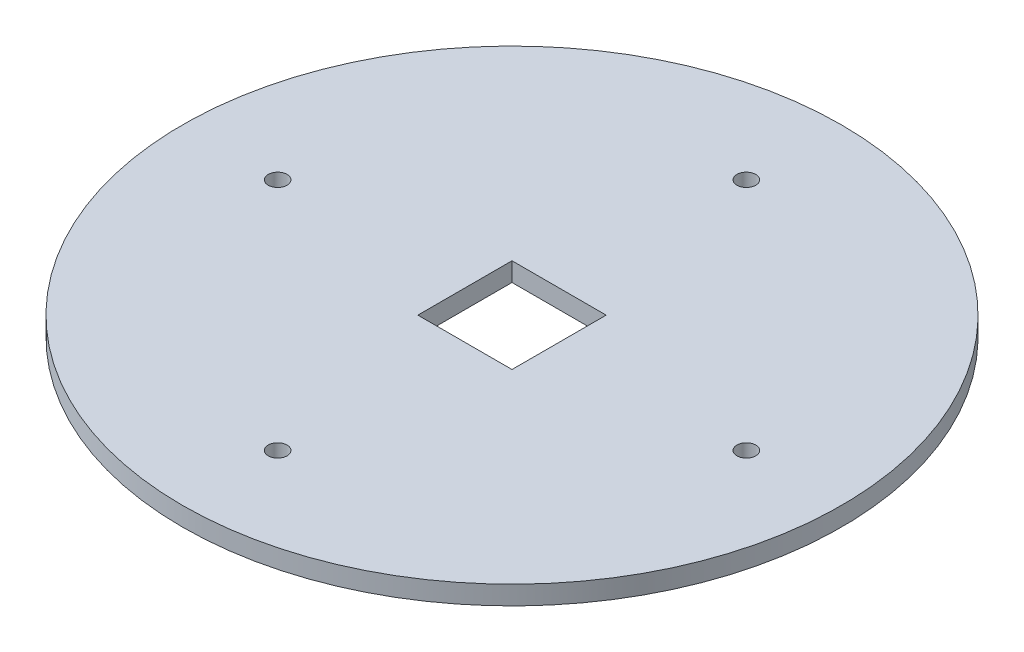
from build123d import *

# Parameters (mm, degrees)
SKETCH1_R           = 35
SKETCH1_R_2         = 1
SKETCH1_W           = 10
SKETCH1_H           = 10
BOSS_EXTRUDE1_DEPTH = 2


with BuildPart() as part:
    # Sketch1 → Boss-Extrude1 (new body)
    with BuildSketch(Plane(origin=(0, 0, 0), x_dir=(1, 0, 0), z_dir=(0, 1, 0))):
        Circle(SKETCH1_R)
        with Locations((0, 24.89)):
            Circle(SKETCH1_R_2, mode=Mode.SUBTRACT)
        with Locations((24.89, 0)):
            Circle(SKETCH1_R_2, mode=Mode.SUBTRACT)
        with Locations((0, -24.89)):
            Circle(SKETCH1_R_2, mode=Mode.SUBTRACT)
        with Locations((-24.89, 0)):
            Circle(SKETCH1_R_2, mode=Mode.SUBTRACT)
        Rectangle(SKETCH1_W, SKETCH1_H, mode=Mode.SUBTRACT)
    extrude(amount=BOSS_EXTRUDE1_DEPTH)


solid = part.part
